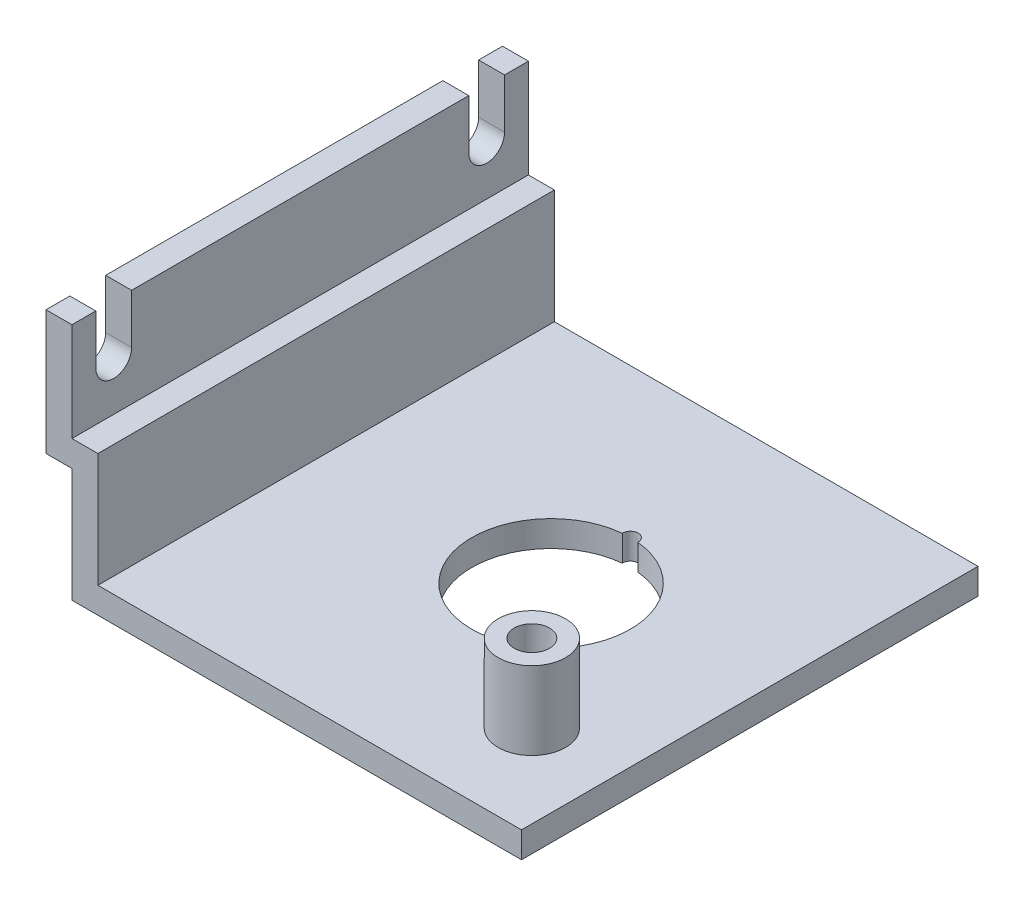
from build123d import *

# Parameters (mm, degrees)
P_IDAT_VYSUNUT_M1_DEPTH  = 88
ODEBRAT_VYSUNUT_M1_REACH = 93.66
ODEBRAT_VYSUNUT_M2_REACH = 48
SKICA4_R                 = 6.5
P_IDAT_VYSUNUT_M2_DEPTH  = 15
M8_Z_VIT1_D              = 6.8
M8_Z_VIT1_DEPTH          = 14
M8_Z_VIT1_TIP            = 2.042926105


with BuildPart() as part:
    # Skica1 → Přidat vysunutím1 (new body)
    with BuildSketch(Plane.XY):
        Polygon((0, 0), (0, 22), (-5, 22), (-5, 46), (0, 46), (0, 27), (5, 27), (5, 5), (86.66, 5), (86.66, 0), align=None)
    extrude(amount=P_IDAT_VYSUNUT_M1_DEPTH)

    # Skica2 → Odebrat vysunutím1 (cut, up to next)
    with BuildSketch(Plane.ZY.offset(5), mode=Mode.PRIVATE) as odebrat_vysunut_m1_sk1:
        with BuildLine():
            Line((4.6, 46), (4.6, 36.45))
            ThreePointArc((4.6, 36.45), (8.05, 33), (11.5, 36.45))
            Line((11.5, 36.45), (11.5, 46))
            Line((11.5, 46), (4.6, 46))
        make_face()
    odebrat_vysunut_m1_tool1 = extrude(odebrat_vysunut_m1_sk1.sketch, amount=-ODEBRAT_VYSUNUT_M1_REACH, mode=Mode.PRIVATE) & part.part
    add(odebrat_vysunut_m1_tool1.solids().sort_by_distance((-5, 39.846006, 8.05))[0], mode=Mode.SUBTRACT)
    # Skica2 → Odebrat vysunutím1 (cut, up to next)
    with BuildSketch(Plane.ZY.offset(5), mode=Mode.PRIVATE) as odebrat_vysunut_m1_sk2:
        with BuildLine():
            Line((83.4, 46), (76.5, 46))
            Line((76.5, 46), (76.5, 36.45))
            ThreePointArc((76.5, 36.45), (79.95, 33), (83.4, 36.45))
            Line((83.4, 36.45), (83.4, 46))
        make_face()
    odebrat_vysunut_m1_tool2 = extrude(odebrat_vysunut_m1_sk2.sketch, amount=-ODEBRAT_VYSUNUT_M1_REACH, mode=Mode.PRIVATE) & part.part
    add(odebrat_vysunut_m1_tool2.solids().sort_by_distance((-5, 39.846006, 79.95))[0], mode=Mode.SUBTRACT)

    # Skica3 → Odebrat vysunutím2 (cut, up to next)
    with BuildSketch(Plane.XZ, mode=Mode.PRIVATE) as odebrat_vysunut_m2_sk1:
        with BuildLine():
            ThreePointArc((49.858196725, 28.773529412), (48.36, 59.3), (46.861803275, 28.773529412))
            ThreePointArc((46.861803275, 28.773529412), (48.36, 27.2), (49.858196725, 28.773529412))
        make_face()
    odebrat_vysunut_m2_tool1 = extrude(odebrat_vysunut_m2_sk1.sketch, amount=-ODEBRAT_VYSUNUT_M2_REACH, mode=Mode.PRIVATE) & part.part
    add(odebrat_vysunut_m2_tool1.solids().sort_by_distance((48.36, 0, 43.922265))[0], mode=Mode.SUBTRACT)

    # Skica4 → Přidat vysunutím2 (add)
    with BuildSketch(Plane(origin=(0, 5, 0), x_dir=(1, 0, 0), z_dir=(0, 1, 0))):
        with Locations((70.66, -70)):
            Circle(SKICA4_R)
    extrude(amount=P_IDAT_VYSUNUT_M2_DEPTH)

    # M8 závit1
    with Locations(Plane(origin=(0, 20, 0), x_dir=(1, 0, 0), z_dir=(0, 1, 0))):
        with Locations((70.66, -70)):
            Hole(M8_Z_VIT1_D / 2, depth=M8_Z_VIT1_DEPTH)
            with Locations((0, 0, -(M8_Z_VIT1_DEPTH + M8_Z_VIT1_TIP / 2))):  # 118° drill point
                Cone(0, M8_Z_VIT1_D / 2, M8_Z_VIT1_TIP, mode=Mode.SUBTRACT)


solid = part.part
